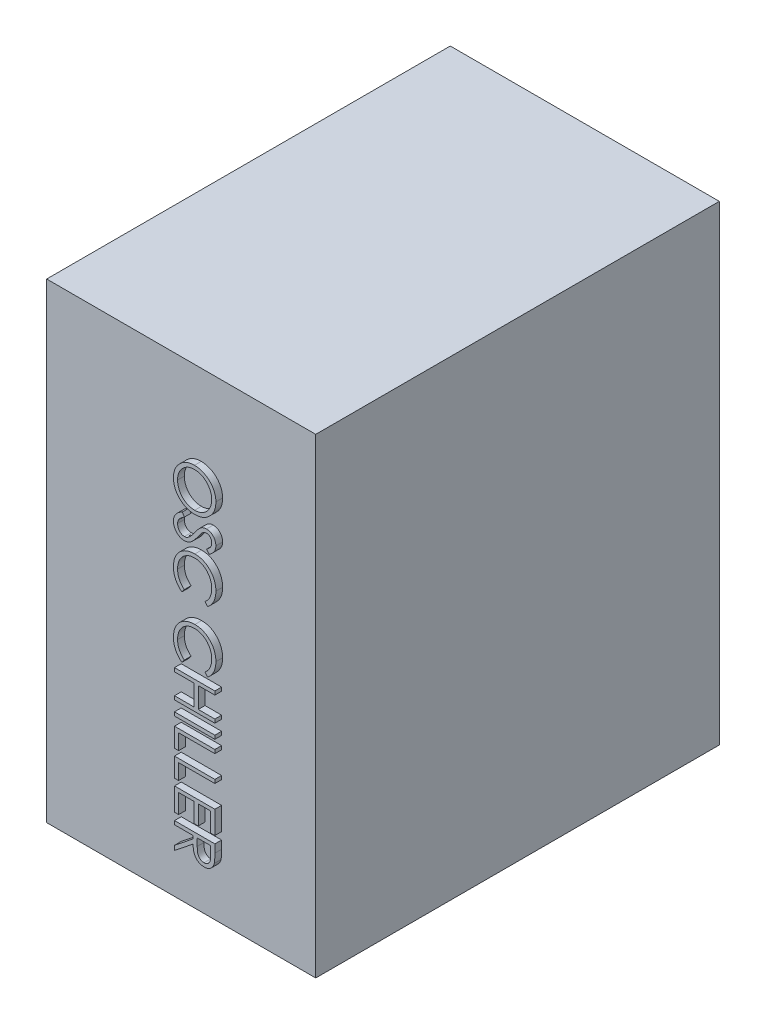
from build123d import *

# Parameters (mm, degrees)
SKETCH1_W           = 200
SKETCH1_H           = 350
BOSS_EXTRUDE1_DEPTH = 300
SKETCH2_W           = 30
SKETCH2_H           = 2.692307692
BOSS_EXTRUDE2_DEPTH = 5


with BuildPart() as part:
    # Sketch1 → Boss-Extrude1 (new body)
    with BuildSketch(Plane.XY):
        with Locations((-100, -175)):
            Rectangle(SKETCH1_W, SKETCH1_H)
    extrude(amount=BOSS_EXTRUDE1_DEPTH)

    # Sketch2 → Boss-Extrude2 (add)
    with BuildSketch(Plane.XY.offset(300)):
        with BuildLine():
            add(Edge.make_bspline(
                [(-69.230769231, -75.576923077), (-69.244839182, -76.132421016), (-69.272473727, -77.223464799), (-69.484007079, -78.82696551), (-69.849974239, -80.357774794), (-70.337346882, -81.828397209), (-70.987617266, -83.221115757), (-71.773152833, -84.546885839), (-72.705125751, -85.801958999), (-73.767897944, -86.974830976), (-74.92845251, -88.044179945), (-76.170543806, -88.978462774), (-77.47716333, -89.768391846), (-78.852857774, -90.41584132), (-80.291572216, -90.924230856), (-81.801486923, -91.274933956), (-83.37268077, -91.498983867), (-84.444340485, -91.525175057), (-84.987980769, -91.538461538)],
                knots=[0, 0, 0, 0, 0.001666225, 0.003272603, 0.004841055, 0.006382296, 0.007912212, 0.00944273, 0.010998049, 0.012593633, 0.014184377, 0.015725243, 0.017248535, 0.018756673, 0.0202791, 0.021816927, 0.023400287, 0.025030489, 0.025030489, 0.025030489, 0.025030489], degree=3))
            add(Edge.make_bspline(
                [(-84.987980769, -91.538461538), (-85.527616489, -91.525177027), (-86.59130101, -91.498991716), (-88.152523859, -91.274678956), (-89.653325755, -90.922931826), (-91.091055576, -90.420557273), (-92.467770578, -89.77621815), (-93.776791804, -88.980950308), (-95.027483464, -88.052853036), (-96.193671994, -86.987200176), (-97.265121686, -85.826922372), (-98.200857074, -84.581328469), (-99.000512052, -83.275994851), (-99.643520724, -81.901132042), (-100.155508264, -80.472067481), (-100.504909784, -78.975703847), (-100.730201885, -77.418718049), (-100.756078383, -76.356968702), (-100.769230769, -75.817307692)],
                knots=[0, 0, 0, 0, 0.001618194, 0.003189648, 0.004721629, 0.006236398, 0.007749974, 0.009273266, 0.010823759, 0.012414889, 0.014005633, 0.015554914, 0.01708132, 0.018589459, 0.020100551, 0.021626686, 0.023192188, 0.024810382, 0.024810382, 0.024810382, 0.024810382], degree=3))
            add(Edge.make_bspline(
                [(-100.769230769, -75.817307692), (-100.755952093, -75.27366961), (-100.729776286, -74.202014235), (-100.50533869, -72.628854888), (-100.154506943, -71.117846903), (-99.652654669, -69.673642651), (-99.006511212, -68.295768205), (-98.212496859, -66.984356826), (-97.276859994, -65.737832646), (-96.212625915, -64.568880493), (-95.051790493, -63.500616248), (-93.814383937, -62.561016158), (-92.512174692, -61.771579465), (-91.150530711, -61.125163242), (-89.732971608, -60.613872622), (-88.250580408, -60.264941869), (-86.71166376, -60.039213902), (-85.663868395, -60.013199728), (-85.132211538, -60)],
                knots=[0, 0, 0, 0, 0.001630202, 0.003213561, 0.004757237, 0.006277682, 0.007791258, 0.00931455, 0.010868637, 0.012459767, 0.014050512, 0.015594994, 0.017113145, 0.01861042, 0.020110189, 0.021624636, 0.023172284, 0.024766464, 0.024766464, 0.024766464, 0.024766464], degree=3))
            add(Edge.make_bspline(
                [(-85.132211538, -60), (-84.775358458, -60.004578388), (-84.066154158, -60.013677405), (-83.013035868, -60.123382311), (-81.976740292, -60.282250886), (-80.960750954, -60.51112543), (-79.964901947, -60.806354177), (-78.991229835, -61.170173523), (-78.031714423, -61.587110634), (-77.104616991, -62.083531858), (-76.208482392, -62.625142269), (-75.354516045, -63.215714005), (-74.557972095, -63.859364806), (-73.806051358, -64.546900273), (-73.111587411, -65.287837437), (-72.459439339, -66.071025216), (-71.856357941, -66.900561604), (-71.315009585, -67.777758534), (-70.817774543, -68.680251538), (-70.402624202, -69.614588245), (-70.035686975, -70.561055092), (-69.744080691, -71.527988928), (-69.512018673, -72.513153077), (-69.354338396, -73.517779101), (-69.244389729, -74.540832248), (-69.235328931, -75.230073544), (-69.230769231, -75.576923077)],
                knots=[0, 0, 0, 0, 0.001070133, 0.002126767, 0.003173079, 0.004214061, 0.005248449, 0.006286635, 0.007330666, 0.008384476, 0.009438833, 0.010470756, 0.011496589, 0.012508848, 0.0135249, 0.014540578, 0.015564755, 0.016598636, 0.017631258, 0.018653335, 0.019663397, 0.020674764, 0.021680598, 0.022697236, 0.023723966, 0.024764064, 0.024764064, 0.024764064, 0.024764064], degree=3))
        make_face()
        with BuildLine():
            add(Edge.make_bspline(
                [(-72.307692308, -75.709134615), (-72.311161143, -75.424437107), (-72.318065653, -74.857763817), (-72.409081928, -74.015334542), (-72.538674716, -73.183938934), (-72.724002335, -72.363622228), (-72.974187899, -71.558798867), (-73.268978217, -70.761431598), (-73.615754353, -69.975349097), (-74.020103961, -69.209339208), (-74.461811996, -68.464682316), (-74.946601873, -67.757196312), (-75.472122874, -67.093938849), (-76.031433215, -66.472785272), (-76.630223664, -65.895545614), (-77.25893748, -65.350518834), (-77.93567373, -64.859640764), (-78.642047093, -64.409763296), (-79.377146776, -64.007182101), (-80.133231198, -63.649193268), (-80.916468543, -63.356358927), (-81.718361315, -63.117538554), (-82.537639542, -62.919540176), (-83.380518246, -62.794106541), (-84.242762064, -62.702114889), (-84.82546367, -62.695601927), (-85.120192308, -62.692307692)],
                knots=[0, 0, 0, 0, 0.000853704, 0.001699246, 0.002539046, 0.003377317, 0.004219457, 0.005065618, 0.005926589, 0.006794828, 0.007662629, 0.008522761, 0.009365586, 0.01019956, 0.011028299, 0.011859387, 0.012693577, 0.013533828, 0.014370288, 0.015206403, 0.016041307, 0.016875951, 0.017715578, 0.018567249, 0.019430733, 0.020314473, 0.020314473, 0.020314473, 0.020314473], degree=3))
            add(Edge.make_bspline(
                [(-85.120192308, -62.692307692), (-85.553582772, -62.703235081), (-86.406195888, -62.724732634), (-87.655637122, -62.912940377), (-88.856393862, -63.202843016), (-90.001895941, -63.630191871), (-91.101989794, -64.164625711), (-92.146916406, -64.824856199), (-93.136958186, -65.607076932), (-94.065203349, -66.495621446), (-94.912453099, -67.466958931), (-95.656139459, -68.498382331), (-96.285370172, -69.578841823), (-96.797985078, -70.711154989), (-97.204182831, -71.889276752), (-97.482571097, -73.120798619), (-97.665789286, -74.397516844), (-97.683384337, -75.267779602), (-97.692307692, -75.709134615)],
                knots=[0, 0, 0, 0, 0.001299467, 0.002556454, 0.003782254, 0.004999108, 0.00621663, 0.007445446, 0.008699383, 0.009995804, 0.011294951, 0.012560828, 0.013804935, 0.01503938, 0.016284183, 0.017536406, 0.018822309, 0.020145531, 0.020145531, 0.020145531, 0.020145531], degree=3))
            add(Edge.make_bspline(
                [(-97.692307692, -75.709134615), (-97.688231953, -76.005787495), (-97.680148537, -76.594139252), (-97.59873113, -77.469243605), (-97.468172911, -78.328583029), (-97.280193421, -79.170949422), (-97.044940682, -79.995397021), (-96.765412245, -80.805328801), (-96.416842839, -81.592260445), (-96.03109703, -82.365579887), (-95.594507348, -83.1059351), (-95.116493864, -83.8083523), (-94.600371229, -84.468759284), (-94.045917856, -85.088586456), (-93.457913286, -85.66982574), (-92.821238949, -86.196694051), (-92.154488662, -86.693452761), (-91.446467682, -87.14152887), (-90.709818934, -87.543309664), (-89.950870561, -87.892682979), (-89.172230808, -88.189264173), (-88.372579981, -88.428639758), (-87.553489365, -88.616232563), (-86.713848051, -88.745488169), (-85.855339575, -88.835903587), (-85.274677928, -88.842718503), (-84.981971154, -88.846153846)],
                knots=[0, 0, 0, 0, 0.000889748, 0.001764637, 0.002634123, 0.003495848, 0.004351876, 0.005205262, 0.006063817, 0.00693191, 0.007796648, 0.008640073, 0.009479184, 0.010309142, 0.011133578, 0.011956895, 0.012786244, 0.013626494, 0.014468227, 0.01530181, 0.016131094, 0.016965738, 0.01780401, 0.018649744, 0.019513228, 0.020390961, 0.020390961, 0.020390961, 0.020390961], degree=3))
            add(Edge.make_bspline(
                [(-84.981971154, -88.846153846), (-84.691266832, -88.842715735), (-84.114601259, -88.835895608), (-83.262079958, -88.74553154), (-82.428481003, -88.616095337), (-81.617076977, -88.429557839), (-80.827661048, -88.18912795), (-80.060974639, -87.892665118), (-79.314161538, -87.543076837), (-78.589067565, -87.141863485), (-77.893284095, -86.690870713), (-77.228120564, -86.198062911), (-76.606068474, -85.654931362), (-76.011771179, -85.076993982), (-75.457903243, -84.449815054), (-74.944282823, -83.776235051), (-74.458507382, -83.064433392), (-74.020305588, -82.310766421), (-73.615547363, -81.532979649), (-73.269063138, -80.734791707), (-72.972912976, -79.923846499), (-72.725026393, -79.104296029), (-72.538493145, -78.270366891), (-72.409128423, -77.42691541), (-72.318055907, -76.572499908), (-72.311157803, -75.997836296), (-72.307692308, -75.709134615)],
                knots=[0, 0, 0, 0, 0.000871726, 0.001729229, 0.002569028, 0.003401441, 0.004224583, 0.005042641, 0.005865322, 0.00669652, 0.007526652, 0.008351175, 0.00917771, 0.010002145, 0.010836595, 0.011685207, 0.012541951, 0.013420096, 0.014299001, 0.015170975, 0.016028415, 0.016887811, 0.017737805, 0.018589476, 0.019446979, 0.020312697, 0.020312697, 0.020312697, 0.020312697], degree=3))
        make_face(mode=Mode.SUBTRACT)
        with BuildLine():
            Line((-94.212740385, -94.615384615), (-92.692307692, -97.151442308))
            add(Edge.make_bspline(
                [(-92.692307692, -97.151442308), (-93.087145278, -97.387312913), (-93.843638854, -97.83923189), (-94.865850629, -98.593100682), (-95.734669116, -99.374239921), (-96.445040037, -100.188434208), (-97.004316209, -101.030713764), (-97.400335338, -101.906577081), (-97.647329413, -102.813072602), (-97.677330155, -103.429991072), (-97.692307692, -103.737980769)],
                knots=[0, 0, 0, 0, 0.001379151, 0.0026424, 0.003803812, 0.004877399, 0.005875827, 0.00682529, 0.007750887, 0.008673672, 0.008673672, 0.008673672, 0.008673672], degree=3))
            add(Edge.make_bspline(
                [(-97.692307692, -103.737980769), (-97.684981937, -104.001011029), (-97.67045861, -104.522469138), (-97.530908744, -105.290145109), (-97.316519575, -106.035704915), (-97.00948112, -106.743773335), (-96.638015244, -107.404613179), (-96.189309619, -107.984027828), (-95.687056245, -108.485247563), (-95.126322424, -108.894119664), (-94.525354599, -109.211529727), (-93.902971508, -109.44121643), (-93.261910813, -109.587398203), (-92.827291013, -109.60600421), (-92.608173077, -109.615384615)],
                knots=[0, 0, 0, 0, 0.000788383, 0.001562971, 0.002333163, 0.003111217, 0.003873017, 0.004601446, 0.005302617, 0.005994975, 0.006675125, 0.007334897, 0.007980868, 0.008637678, 0.008637678, 0.008637678, 0.008637678], degree=3))
            add(Edge.make_bspline(
                [(-92.608173077, -109.615384615), (-92.358394365, -109.602747667), (-91.850630744, -109.577058596), (-91.101490861, -109.359931624), (-90.360125975, -109.018366651), (-89.901543699, -108.703258277), (-89.663461538, -108.539663462)],
                knots=[0, 0, 0, 0, 0.000748119, 0.001520816, 0.00232208, 0.003187236, 0.003187236, 0.003187236, 0.003187236], degree=3))
            add(Edge.make_bspline(
                [(-89.663461538, -108.539663462), (-89.49128036, -108.405724167), (-89.128746457, -108.123709978), (-88.598128141, -107.632166941), (-88.03742092, -107.070380755), (-87.448901697, -106.435542902), (-86.8433183, -105.715034125), (-86.20804728, -104.923649192), (-85.544997869, -104.057291433), (-85.106529765, -103.446721635), (-84.879807692, -103.131009615)],
                knots=[0, 0, 0, 0, 0.000654165, 0.00137737, 0.002167765, 0.003035317, 0.003973318, 0.004990702, 0.006079687, 0.007245691, 0.007245691, 0.007245691, 0.007245691], degree=3))
            add(Edge.make_bspline(
                [(-84.879807692, -103.131009615), (-84.654939769, -102.815417465), (-84.225009425, -102.212029305), (-83.587752235, -101.367554299), (-83.001405211, -100.613420214), (-82.47413595, -99.945784361), (-81.982947637, -99.381919327), (-81.554165222, -98.90121178), (-81.164892213, -98.521396842), (-80.912566756, -98.310038787), (-80.799278846, -98.215144231)],
                knots=[0, 0, 0, 0, 0.001162484, 0.002222581, 0.00317343, 0.004028445, 0.004774146, 0.0054165, 0.005960495, 0.006403742, 0.006403742, 0.006403742, 0.006403742], degree=3))
            add(Edge.make_bspline(
                [(-80.799278846, -98.215144231), (-80.62269853, -98.082522415), (-80.275429641, -97.821703814), (-79.732645146, -97.477423767), (-79.177017156, -97.184802372), (-78.607052603, -96.955410954), (-78.030753213, -96.762243363), (-77.440599678, -96.632318243), (-76.839240091, -96.550963412), (-76.434552943, -96.542632099), (-76.231971154, -96.538461538)],
                knots=[0, 0, 0, 0, 0.000662313, 0.001302528, 0.001926139, 0.002543289, 0.00314383, 0.00374743, 0.004353448, 0.004960895, 0.004960895, 0.004960895, 0.004960895], degree=3))
            add(Edge.make_bspline(
                [(-76.231971154, -96.538461538), (-75.914546511, -96.549600243), (-75.286481954, -96.57163957), (-74.369460405, -96.759552039), (-73.491277886, -97.052683073), (-72.671278081, -97.47663637), (-71.911378568, -98.000799625), (-71.223189369, -98.620278255), (-70.639724258, -99.355772773), (-70.135851409, -100.16725206), (-69.738022725, -101.049746606), (-69.436329048, -101.972837889), (-69.267663808, -102.940573698), (-69.243188261, -103.597142011), (-69.230769231, -103.930288462)],
                knots=[0, 0, 0, 0, 0.000951419, 0.001882502, 0.002796616, 0.003721179, 0.004641357, 0.005560219, 0.006487513, 0.007448149, 0.008418995, 0.00938447, 0.010354701, 0.011354106, 0.011354106, 0.011354106, 0.011354106], degree=3))
            add(Edge.make_bspline(
                [(-69.230769231, -103.930288462), (-69.242734118, -104.283862018), (-69.26646192, -104.98504066), (-69.480156343, -106.018378206), (-69.825340494, -107.01518196), (-70.222908912, -107.817560139), (-70.618205127, -108.444449792), (-70.978400721, -108.922493502), (-71.393036884, -109.406931255), (-71.863261246, -109.901656712), (-72.393375591, -110.398291151), (-72.979753119, -110.904206393), (-73.618809256, -111.420585858), (-74.07501927, -111.752778942), (-74.308894231, -111.923076923)],
                knots=[0, 0, 0, 0, 0.001059756, 0.002101623, 0.00315071, 0.004217683, 0.004779542, 0.005372091, 0.006011544, 0.006691667, 0.007418631, 0.008189761, 0.009014744, 0.009882546, 0.009882546, 0.009882546, 0.009882546], degree=3))
            Line((-74.308894231, -111.923076923), (-76.153846154, -109.489182692))
            add(Edge.make_bspline(
                [(-76.153846154, -109.489182692), (-75.964514516, -109.342217559), (-75.59990605, -109.059197073), (-75.089294843, -108.629515734), (-74.622867639, -108.224527399), (-74.217738754, -107.825523723), (-73.851717907, -107.453579126), (-73.538356979, -107.092573227), (-73.274538831, -106.747716061), (-72.993136677, -106.312963361), (-72.712417205, -105.765372829), (-72.479933556, -105.078666378), (-72.335196286, -104.362994221), (-72.31696108, -103.876889737), (-72.307692308, -103.629807692)],
                knots=[0, 0, 0, 0, 0.000718947, 0.001384524, 0.002001878, 0.002571367, 0.003089868, 0.003567018, 0.004004524, 0.004391247, 0.005119601, 0.005843679, 0.006560261, 0.007301005, 0.007301005, 0.007301005, 0.007301005], degree=3))
            add(Edge.make_bspline(
                [(-72.307692308, -103.629807692), (-72.318078307, -103.319894643), (-72.338106729, -102.722256522), (-72.55684946, -101.873768784), (-72.901265406, -101.11010657), (-73.383965218, -100.453941726), (-73.955859441, -99.90762478), (-74.613963913, -99.512435134), (-75.340670221, -99.27457658), (-75.847598704, -99.245551326), (-76.105769231, -99.230769231)],
                knots=[0, 0, 0, 0, 0.000927839, 0.00178925, 0.002609402, 0.003426798, 0.004217605, 0.004966882, 0.00571188, 0.006485068, 0.006485068, 0.006485068, 0.006485068], degree=3))
            add(Edge.make_bspline(
                [(-76.105769231, -99.230769231), (-76.266455212, -99.234295757), (-76.588089927, -99.241354577), (-77.064529679, -99.333162064), (-77.536740241, -99.46334232), (-78.006821339, -99.653869143), (-78.485831991, -99.910500217), (-78.972478926, -100.259441331), (-79.479048809, -100.695981029), (-79.808192958, -101.031034534), (-79.981971154, -101.207932692)],
                knots=[0, 0, 0, 0, 0.00048137, 0.000963527, 0.001450565, 0.001949399, 0.002481785, 0.00307701, 0.003741881, 0.004485545, 0.004485545, 0.004485545, 0.004485545], degree=3))
            add(Edge.make_bspline(
                [(-79.981971154, -101.207932692), (-80.040574232, -101.273601599), (-80.179801732, -101.429615888), (-80.407735566, -101.714838109), (-80.688902186, -102.091490665), (-81.03679347, -102.549738104), (-81.44034886, -103.098029776), (-81.894408392, -103.736425971), (-82.413712327, -104.457810539), (-82.776776961, -104.969712675), (-82.96875, -105.240384615)],
                knots=[0, 0, 0, 0, 0.000264013, 0.000627234, 0.001094789, 0.001674117, 0.00235323, 0.003137065, 0.004024292, 0.005019805, 0.005019805, 0.005019805, 0.005019805], degree=3))
            add(Edge.make_bspline(
                [(-82.96875, -105.240384615), (-83.205675939, -105.565978158), (-83.664450183, -106.196444927), (-84.35372744, -107.093509898), (-85.027851171, -107.906885396), (-85.682516374, -108.63942714), (-86.312757171, -109.29837207), (-86.92615586, -109.876409676), (-87.518317912, -110.379429793), (-88.277511417, -110.920965951), (-89.209920711, -111.47431869), (-90.352305613, -111.949531611), (-91.499131217, -112.249174589), (-92.269932673, -112.288359007), (-92.650240385, -112.307692308)],
                knots=[0, 0, 0, 0, 0.001207992, 0.00233911, 0.003393262, 0.004376436, 0.005285975, 0.00612775, 0.006904131, 0.007614614, 0.008923607, 0.010146797, 0.011317207, 0.012457087, 0.012457087, 0.012457087, 0.012457087], degree=3))
            add(Edge.make_bspline(
                [(-92.650240385, -112.307692308), (-92.919195679, -112.302056566), (-93.451883339, -112.290894525), (-94.234100545, -112.162703623), (-94.993679043, -111.974651555), (-95.721918028, -111.692109017), (-96.428561941, -111.344555004), (-97.107101593, -110.915275913), (-97.748209184, -110.397780245), (-98.365226098, -109.82260477), (-98.922569761, -109.183393646), (-99.421051245, -108.509406688), (-99.838277116, -107.796268298), (-100.174145018, -107.047430148), (-100.440993804, -106.267034656), (-100.632799136, -105.454260543), (-100.750787971, -104.606844478), (-100.763014539, -104.030835273), (-100.769230769, -103.737980769)],
                knots=[0, 0, 0, 0, 0.000806095, 0.001596537, 0.002371964, 0.003149901, 0.00393468, 0.004731605, 0.005552836, 0.006403107, 0.007259029, 0.008093219, 0.008914692, 0.009732353, 0.010551448, 0.011385227, 0.012234286, 0.01311243, 0.01311243, 0.01311243, 0.01311243], degree=3))
            add(Edge.make_bspline(
                [(-100.769230769, -103.737980769), (-100.764799007, -103.511402115), (-100.755991297, -103.061098332), (-100.67997017, -102.396832354), (-100.568484262, -101.744764316), (-100.398508633, -101.113081715), (-100.187425898, -100.493918957), (-99.928985629, -99.89279507), (-99.621325626, -99.308249593), (-99.263936304, -98.739599939), (-98.852057703, -98.181487792), (-98.376071977, -97.636774435), (-97.839266855, -97.099228296), (-97.236137273, -96.578703427), (-96.573127057, -96.065605196), (-95.844680829, -95.569475587), (-95.054579999, -95.080211945), (-94.498594855, -94.773221058), (-94.212740385, -94.615384615)],
                knots=[0, 0, 0, 0, 0.000679512, 0.001350466, 0.002003554, 0.002662423, 0.003310487, 0.003964652, 0.004623247, 0.005290206, 0.005977722, 0.006701925, 0.007458325, 0.008254888, 0.009090311, 0.009972108, 0.010897706, 0.011877181, 0.011877181, 0.011877181, 0.011877181], degree=3))
        make_face()
        with BuildLine():
            Line((-75.504807692, -146.153846154), (-77.307692308, -143.798076923))
            add(Edge.make_bspline(
                [(-77.307692308, -143.798076923), (-77.107412566, -143.630026451), (-76.709553289, -143.296191193), (-76.150871479, -142.759112314), (-75.627454952, -142.199383946), (-75.13681027, -141.61722005), (-74.696095135, -141.002141883), (-74.282342824, -140.369049323), (-73.911476499, -139.707351793), (-73.461793761, -138.792336925), (-72.992541003, -137.595355368), (-72.599084735, -136.088542462), (-72.348617515, -134.515590189), (-72.321490302, -133.442467906), (-72.307692308, -132.896634615)],
                knots=[0, 0, 0, 0, 0.000784157, 0.001557742, 0.002323066, 0.003082516, 0.003839823, 0.004591601, 0.005350433, 0.006113725, 0.007649331, 0.0091974, 0.010778282, 0.012414764, 0.012414764, 0.012414764, 0.012414764], degree=3))
            add(Edge.make_bspline(
                [(-72.307692308, -132.896634615), (-72.311170467, -132.595924276), (-72.318094506, -131.997294474), (-72.408799291, -131.108825042), (-72.537754174, -130.235263331), (-72.724443141, -129.379857807), (-72.967495238, -128.544306917), (-73.252530473, -127.722248631), (-73.607227895, -126.923364604), (-73.998943843, -126.138040472), (-74.441510876, -125.385681972), (-74.924084567, -124.673670738), (-75.441928528, -124.005259614), (-75.993706049, -123.378596414), (-76.586274614, -122.800553856), (-77.212663356, -122.261867945), (-77.880411642, -121.772247071), (-78.576996415, -121.319659654), (-79.303441518, -120.9169378), (-80.055177007, -120.569167979), (-80.829328725, -120.271100328), (-81.627482571, -120.033060176), (-82.446497616, -119.845303038), (-83.288111995, -119.715591875), (-84.150692089, -119.625703062), (-84.735342563, -119.618842718), (-85.030048077, -119.615384615)],
                knots=[0, 0, 0, 0, 0.000901763, 0.001795156, 0.002676523, 0.003549987, 0.004419224, 0.005285943, 0.006157917, 0.007039448, 0.007917592, 0.008774337, 0.00961819, 0.01045264, 0.011277075, 0.01209969, 0.012929039, 0.013759171, 0.014590369, 0.015418497, 0.016242165, 0.01707681, 0.017915081, 0.018760816, 0.019630281, 0.020514021, 0.020514021, 0.020514021, 0.020514021], degree=3))
            add(Edge.make_bspline(
                [(-85.030048077, -119.615384615), (-85.473459391, -119.626200207), (-86.344038689, -119.647435187), (-87.619215351, -119.836420907), (-88.840821126, -120.123607404), (-90.001219775, -120.554026635), (-91.114719987, -121.084761354), (-92.162481587, -121.755395167), (-93.160337854, -122.532108344), (-94.084705978, -123.425889083), (-94.929109338, -124.406510362), (-95.672685751, -125.458635319), (-96.2925276, -126.5796435), (-96.808321428, -127.757157473), (-97.204807665, -129.000238449), (-97.483928723, -130.306651042), (-97.666004557, -131.673553858), (-97.683436169, -132.607577286), (-97.692307692, -133.082932692)],
                knots=[0, 0, 0, 0, 0.001329484, 0.002610265, 0.003859413, 0.005087552, 0.006315883, 0.007552988, 0.008811655, 0.010103736, 0.011403495, 0.012688963, 0.013961441, 0.01523981, 0.016539777, 0.017868228, 0.019243498, 0.020668804, 0.020668804, 0.020668804, 0.020668804], degree=3))
            add(Edge.make_bspline(
                [(-97.692307692, -133.082932692), (-97.677832437, -133.606670027), (-97.649341673, -134.637510389), (-97.40797668, -136.149236329), (-97.016623099, -137.596400034), (-96.468926622, -138.979079347), (-95.75693844, -140.293376315), (-94.893813776, -141.541347689), (-93.871342353, -142.724046865), (-93.090629825, -143.435229284), (-92.692307692, -143.798076923)],
                knots=[0, 0, 0, 0, 0.001570454, 0.003091029, 0.004579498, 0.006060378, 0.00754194, 0.009053905, 0.010604642, 0.012219988, 0.012219988, 0.012219988, 0.012219988], degree=3))
            Line((-92.692307692, -143.798076923), (-94.477163462, -146.153846154))
            add(Edge.make_bspline(
                [(-94.477163462, -146.153846154), (-94.721779182, -145.964262607), (-95.209838927, -145.586003606), (-95.897875952, -144.973502585), (-96.545076565, -144.328282551), (-97.146084268, -143.645467445), (-97.713445719, -142.933223741), (-98.22814058, -142.179005623), (-98.705847279, -141.395839903), (-99.137473862, -140.579166873), (-99.52447446, -139.731667779), (-99.851191065, -138.8542246), (-100.136680438, -137.954271082), (-100.369996599, -137.031354004), (-100.552394184, -136.082390154), (-100.674256793, -135.11063545), (-100.757764402, -134.114038621), (-100.765374359, -133.441683295), (-100.769230769, -133.100961538)],
                knots=[0, 0, 0, 0, 0.000928228, 0.00185201, 0.00276139, 0.003668205, 0.004579548, 0.005491368, 0.00640556, 0.007330338, 0.008260898, 0.009198494, 0.010137418, 0.011092115, 0.012052696, 0.013034399, 0.014029058, 0.015050976, 0.015050976, 0.015050976, 0.015050976], degree=3))
            add(Edge.make_bspline(
                [(-100.769230769, -133.100961538), (-100.766985119, -132.778301535), (-100.762544623, -132.140281334), (-100.690611759, -131.198292035), (-100.592471157, -130.281238485), (-100.444698605, -129.391741692), (-100.270318548, -128.52494762), (-100.03656492, -127.688714039), (-99.77471492, -126.874812236), (-99.466957891, -126.086512173), (-99.119676326, -125.323143317), (-98.72717725, -124.587167791), (-98.292761267, -123.878924085), (-97.826004035, -123.191449049), (-97.311912876, -122.534898332), (-96.757627438, -121.9035824), (-96.165015917, -121.293961175), (-95.737688602, -120.916795304), (-95.522836538, -120.727163462)],
                knots=[0, 0, 0, 0, 0.000967716, 0.001913539, 0.002832695, 0.003733737, 0.004617702, 0.005483692, 0.006336994, 0.00718181, 0.008020856, 0.008851597, 0.009682316, 0.010512427, 0.011343103, 0.012182063, 0.013031994, 0.013891432, 0.013891432, 0.013891432, 0.013891432], degree=3))
            add(Edge.make_bspline(
                [(-95.522836538, -120.727163462), (-95.149626348, -120.423429374), (-94.407711687, -119.819628144), (-93.205260419, -119.047122285), (-91.949818629, -118.385857526), (-90.634790668, -117.851206777), (-89.263127349, -117.433240493), (-87.834137225, -117.143687392), (-86.349154863, -116.955530782), (-85.339125246, -116.934014021), (-84.825721154, -116.923076923)],
                knots=[0, 0, 0, 0, 0.001442621, 0.002867825, 0.004279061, 0.005694131, 0.007119943, 0.008574344, 0.010063662, 0.011603297, 0.011603297, 0.011603297, 0.011603297], degree=3))
            add(Edge.make_bspline(
                [(-84.825721154, -116.923076923), (-84.286125557, -116.936466776), (-83.224504907, -116.962810476), (-81.666120223, -117.184780607), (-80.175225931, -117.546190862), (-78.746085424, -118.043855192), (-77.386875702, -118.700407503), (-76.091856249, -119.495217173), (-74.862084485, -120.436047571), (-73.713283157, -121.511082766), (-72.662973833, -122.690293476), (-71.738913341, -123.953009924), (-70.969907991, -125.296859467), (-70.327083224, -126.707011332), (-69.832987966, -128.194031772), (-69.48710347, -129.754746278), (-69.271813912, -131.386222714), (-69.244597843, -132.499329217), (-69.230769231, -133.064903846)],
                knots=[0, 0, 0, 0, 0.001618194, 0.003183696, 0.004711238, 0.006214663, 0.007714529, 0.00923068, 0.010765593, 0.012351596, 0.013943634, 0.015496687, 0.017036697, 0.018580501, 0.020138835, 0.021728012, 0.023370144, 0.025066389, 0.025066389, 0.025066389, 0.025066389], degree=3))
            add(Edge.make_bspline(
                [(-69.230769231, -133.064903846), (-69.234898756, -133.409599995), (-69.243072734, -134.091891309), (-69.322884432, -135.101189969), (-69.455693622, -136.083874477), (-69.637651193, -137.04232132), (-69.860670179, -137.980006023), (-70.152619266, -138.887308642), (-70.491643728, -139.769169781), (-70.87215006, -140.626249905), (-71.30715598, -141.44922424), (-71.779618008, -142.237943016), (-72.300442147, -142.982891786), (-72.852409936, -143.698083085), (-73.456168594, -144.367415692), (-74.092056253, -145.010005583), (-74.778941926, -145.603655281), (-75.262409524, -145.970113477), (-75.504807692, -146.153846154)],
                knots=[0, 0, 0, 0, 0.001033933, 0.002046567, 0.003035016, 0.004007405, 0.004972318, 0.005924515, 0.006864246, 0.007805763, 0.008735857, 0.009655191, 0.010562065, 0.011461261, 0.012363584, 0.013264466, 0.014171838, 0.015084212, 0.015084212, 0.015084212, 0.015084212], degree=3))
        make_face()
        with BuildLine():
            Line((-75.504807692, -191.538461538), (-77.307692308, -189.182692308))
            add(Edge.make_bspline(
                [(-77.307692308, -189.182692308), (-77.107412566, -189.014641836), (-76.709553289, -188.680806578), (-76.150871479, -188.143727699), (-75.627454952, -187.583999331), (-75.13681027, -187.001835435), (-74.696095135, -186.386757268), (-74.282342824, -185.753664708), (-73.911476499, -185.091967178), (-73.461793761, -184.176952309), (-72.992541003, -182.979970753), (-72.599084735, -181.473157846), (-72.348617515, -179.900205573), (-72.321490302, -178.827083291), (-72.307692308, -178.28125)],
                knots=[0, 0, 0, 0, 0.000784157, 0.001557742, 0.002323066, 0.003082516, 0.003839823, 0.004591601, 0.005350433, 0.006113725, 0.007649331, 0.0091974, 0.010778282, 0.012414764, 0.012414764, 0.012414764, 0.012414764], degree=3))
            add(Edge.make_bspline(
                [(-72.307692308, -178.28125), (-72.311170467, -177.980539661), (-72.318094506, -177.381909858), (-72.408799291, -176.493440427), (-72.537754174, -175.619878716), (-72.724443141, -174.764473192), (-72.967495238, -173.928922301), (-73.252530473, -173.106864016), (-73.607227895, -172.307979989), (-73.998943843, -171.522655857), (-74.441510876, -170.770297356), (-74.924084567, -170.058286123), (-75.441928528, -169.389874998), (-75.993706049, -168.763211799), (-76.586274614, -168.185169241), (-77.212663356, -167.64648333), (-77.880411642, -167.156862456), (-78.576996415, -166.704275039), (-79.303441518, -166.301553184), (-80.055177007, -165.953783364), (-80.829328725, -165.655715713), (-81.627482571, -165.417675561), (-82.446497616, -165.229918423), (-83.288111995, -165.100207259), (-84.150692089, -165.010318447), (-84.735342563, -165.003458103), (-85.030048077, -165)],
                knots=[0, 0, 0, 0, 0.000901763, 0.001795156, 0.002676523, 0.003549987, 0.004419224, 0.005285943, 0.006157917, 0.007039448, 0.007917592, 0.008774337, 0.00961819, 0.01045264, 0.011277075, 0.01209969, 0.012929039, 0.013759171, 0.014590369, 0.015418497, 0.016242165, 0.01707681, 0.017915081, 0.018760816, 0.019630281, 0.020514021, 0.020514021, 0.020514021, 0.020514021], degree=3))
            add(Edge.make_bspline(
                [(-85.030048077, -165), (-85.473459391, -165.010815592), (-86.344038689, -165.032050571), (-87.619215351, -165.221036292), (-88.840821126, -165.508222789), (-90.001219775, -165.93864202), (-91.114719987, -166.469376739), (-92.162481587, -167.140010552), (-93.160337854, -167.916723729), (-94.084705978, -168.810504467), (-94.929109338, -169.791125747), (-95.672685751, -170.843250704), (-96.2925276, -171.964258885), (-96.808321428, -173.141772858), (-97.204807665, -174.384853834), (-97.483928723, -175.691266426), (-97.666004557, -177.058169243), (-97.683436169, -177.99219267), (-97.692307692, -178.467548077)],
                knots=[0, 0, 0, 0, 0.001329484, 0.002610265, 0.003859413, 0.005087552, 0.006315883, 0.007552988, 0.008811655, 0.010103736, 0.011403495, 0.012688963, 0.013961441, 0.01523981, 0.016539777, 0.017868228, 0.019243498, 0.020668804, 0.020668804, 0.020668804, 0.020668804], degree=3))
            add(Edge.make_bspline(
                [(-97.692307692, -178.467548077), (-97.677832437, -178.991285411), (-97.649341673, -180.022125773), (-97.40797668, -181.533851713), (-97.016623099, -182.981015419), (-96.468926622, -184.363694732), (-95.75693844, -185.677991699), (-94.893813776, -186.925963074), (-93.871342353, -188.108662249), (-93.090629825, -188.819844668), (-92.692307692, -189.182692308)],
                knots=[0, 0, 0, 0, 0.001570454, 0.003091029, 0.004579498, 0.006060378, 0.00754194, 0.009053905, 0.010604642, 0.012219988, 0.012219988, 0.012219988, 0.012219988], degree=3))
            Line((-92.692307692, -189.182692308), (-94.477163462, -191.538461538))
            add(Edge.make_bspline(
                [(-94.477163462, -191.538461538), (-94.721779182, -191.348877991), (-95.209838927, -190.970618991), (-95.897875952, -190.35811797), (-96.545076565, -189.712897935), (-97.146084268, -189.030082829), (-97.713445719, -188.317839126), (-98.22814058, -187.563621008), (-98.705847279, -186.780455287), (-99.137473862, -185.963782258), (-99.52447446, -185.116283164), (-99.851191065, -184.238839984), (-100.136680438, -183.338886467), (-100.369996599, -182.415969389), (-100.552394184, -181.467005539), (-100.674256793, -180.495250835), (-100.757764402, -179.498654005), (-100.765374359, -178.82629868), (-100.769230769, -178.485576923)],
                knots=[0, 0, 0, 0, 0.000928228, 0.00185201, 0.00276139, 0.003668205, 0.004579548, 0.005491368, 0.00640556, 0.007330338, 0.008260898, 0.009198494, 0.010137418, 0.011092115, 0.012052696, 0.013034399, 0.014029058, 0.015050976, 0.015050976, 0.015050976, 0.015050976], degree=3))
            add(Edge.make_bspline(
                [(-100.769230769, -178.485576923), (-100.766985119, -178.16291692), (-100.762544623, -177.524896719), (-100.690611759, -176.582907419), (-100.592471157, -175.66585387), (-100.444698605, -174.776357076), (-100.270318548, -173.909563005), (-100.03656492, -173.073329423), (-99.77471492, -172.25942762), (-99.466957891, -171.471127557), (-99.119676326, -170.707758702), (-98.72717725, -169.971783176), (-98.292761267, -169.263539469), (-97.826004035, -168.576064434), (-97.311912876, -167.919513716), (-96.757627438, -167.288197785), (-96.165015917, -166.67857656), (-95.737688602, -166.301410689), (-95.522836538, -166.111778846)],
                knots=[0, 0, 0, 0, 0.000967716, 0.001913539, 0.002832695, 0.003733737, 0.004617702, 0.005483692, 0.006336994, 0.00718181, 0.008020856, 0.008851597, 0.009682316, 0.010512427, 0.011343103, 0.012182063, 0.013031994, 0.013891432, 0.013891432, 0.013891432, 0.013891432], degree=3))
            add(Edge.make_bspline(
                [(-95.522836538, -166.111778846), (-95.149626348, -165.808044759), (-94.407711687, -165.204243529), (-93.205260419, -164.43173767), (-91.949818629, -163.770472911), (-90.634790668, -163.235822162), (-89.263127349, -162.817855877), (-87.834137225, -162.528302777), (-86.349154863, -162.340146167), (-85.339125246, -162.318629406), (-84.825721154, -162.307692308)],
                knots=[0, 0, 0, 0, 0.001442621, 0.002867825, 0.004279061, 0.005694131, 0.007119943, 0.008574344, 0.010063662, 0.011603297, 0.011603297, 0.011603297, 0.011603297], degree=3))
            add(Edge.make_bspline(
                [(-84.825721154, -162.307692308), (-84.286125557, -162.321082161), (-83.224504907, -162.347425861), (-81.666120223, -162.569395992), (-80.175225931, -162.930806247), (-78.746085424, -163.428470577), (-77.386875702, -164.085022888), (-76.091856249, -164.879832558), (-74.862084485, -165.820662956), (-73.713283157, -166.895698151), (-72.662973833, -168.07490886), (-71.738913341, -169.337625309), (-70.969907991, -170.681474851), (-70.327083224, -172.091626717), (-69.832987966, -173.578647156), (-69.48710347, -175.139361663), (-69.271813912, -176.770838099), (-69.244597843, -177.883944601), (-69.230769231, -178.449519231)],
                knots=[0, 0, 0, 0, 0.001618194, 0.003183696, 0.004711238, 0.006214663, 0.007714529, 0.00923068, 0.010765593, 0.012351596, 0.013943634, 0.015496687, 0.017036697, 0.018580501, 0.020138835, 0.021728012, 0.023370144, 0.025066389, 0.025066389, 0.025066389, 0.025066389], degree=3))
            add(Edge.make_bspline(
                [(-69.230769231, -178.449519231), (-69.234898756, -178.79421538), (-69.243072734, -179.476506694), (-69.322884432, -180.485805353), (-69.455693622, -181.468489861), (-69.637651193, -182.426936704), (-69.860670179, -183.364621407), (-70.152619266, -184.271924027), (-70.491643728, -185.153785166), (-70.87215006, -186.01086529), (-71.30715598, -186.833839624), (-71.779618008, -187.622558401), (-72.300442147, -188.367507171), (-72.852409936, -189.082698469), (-73.456168594, -189.752031077), (-74.092056253, -190.394620967), (-74.778941926, -190.988270665), (-75.262409524, -191.354728862), (-75.504807692, -191.538461538)],
                knots=[0, 0, 0, 0, 0.001033933, 0.002046567, 0.003035016, 0.004007405, 0.004972318, 0.005924515, 0.006864246, 0.007805763, 0.008735857, 0.009655191, 0.010562065, 0.011461261, 0.012363584, 0.013264466, 0.014171838, 0.015084212, 0.015084212, 0.015084212, 0.015084212], degree=3))
        make_face()
        Polygon((-70, -197.692307692), (-70, -200.384615385), (-82.307692308, -200.384615385), (-82.307692308, -215.769230769), (-70, -215.769230769), (-70, -218.461538462), (-100, -218.461538462), (-100, -215.769230769), (-85.384615385, -215.769230769), (-85.384615385, -200.384615385), (-100, -200.384615385), (-100, -197.692307692), align=None)
        with Locations((-85, -227.5)):
            Rectangle(SKETCH2_W, SKETCH2_H)
        Polygon((-70, -235.384615385), (-70, -238.076923077), (-96.923076923, -238.076923077), (-96.923076923, -249.615384615), (-100, -249.615384615), (-100, -235.384615385), align=None)
        Polygon((-70, -254.615384615), (-70, -257.307692308), (-96.923076923, -257.307692308), (-96.923076923, -268.846153846), (-100, -268.846153846), (-100, -254.615384615), align=None)
        Polygon((-70, -273.846153846), (-70, -290.769230769), (-73.076923077, -290.769230769), (-73.076923077, -276.538461538), (-82.307692308, -276.538461538), (-82.307692308, -290.769230769), (-85.384615385, -290.769230769), (-85.384615385, -276.538461538), (-96.923076923, -276.538461538), (-96.923076923, -290.769230769), (-100, -290.769230769), (-100, -273.846153846), align=None)
        with BuildLine():
            Line((-70, -296.153846154), (-70, -302.157451923))
            add(Edge.make_bspline(
                [(-70, -302.157451923), (-70.001333594, -302.558090167), (-70.003894243, -303.327359977), (-70.018172211, -304.42941658), (-70.059095259, -305.430791697), (-70.094311689, -306.330961748), (-70.158528329, -307.129910219), (-70.219905304, -307.830086997), (-70.300250968, -308.428267262), (-70.374868879, -308.790374558), (-70.408653846, -308.954326923)],
                knots=[0, 0, 0, 0, 0.001201938, 0.002307854, 0.003306102, 0.004208525, 0.00501006, 0.005710303, 0.006317125, 0.006819207, 0.006819207, 0.006819207, 0.006819207], degree=3))
            add(Edge.make_bspline(
                [(-70.408653846, -308.954326923), (-70.462877112, -309.173816139), (-70.570166913, -309.60811227), (-70.797052743, -310.233342462), (-71.05917739, -310.829386451), (-71.369442173, -311.394007458), (-71.722435407, -311.92725786), (-72.120219502, -312.428339237), (-72.564820221, -312.894386763), (-73.044884334, -313.328986448), (-73.564600544, -313.722937076), (-74.116397994, -314.0638498), (-74.696825515, -314.355771654), (-75.307904369, -314.588821649), (-75.944468889, -314.776303226), (-76.612077484, -314.908540242), (-77.307745656, -314.987832789), (-77.782241648, -314.995906298), (-78.022836538, -315)],
                knots=[0, 0, 0, 0, 0.000677836, 0.001341211, 0.001992277, 0.002629693, 0.003271401, 0.003908675, 0.004546318, 0.005201614, 0.005849455, 0.006499855, 0.007144875, 0.007795525, 0.008459227, 0.009133376, 0.009834856, 0.01055641, 0.01055641, 0.01055641, 0.01055641], degree=3))
            add(Edge.make_bspline(
                [(-78.022836538, -315), (-78.422566467, -314.987408914), (-79.202543089, -314.962840445), (-80.334487076, -314.733763564), (-81.390418982, -314.358552943), (-82.368869317, -313.841434685), (-83.251280919, -313.183209624), (-84.023710393, -312.392172777), (-84.676062277, -311.472363915), (-85.123633165, -310.612062019), (-85.411619459, -309.851755871), (-85.615264878, -309.223987271), (-85.76995325, -308.538677865), (-85.910543367, -307.805659457), (-86.01782492, -307.019270139), (-86.094015213, -306.181093506), (-86.14300615, -305.28903323), (-86.150163936, -304.677549558), (-86.153846154, -304.362980769)],
                knots=[0, 0, 0, 0, 0.001198086, 0.002337776, 0.003447848, 0.004550084, 0.005645039, 0.006737219, 0.007852889, 0.009016724, 0.009635014, 0.010290723, 0.010994772, 0.01174086, 0.012529564, 0.013374529, 0.014265251, 0.015208933, 0.015208933, 0.015208933, 0.015208933], degree=3))
            Line((-86.153846154, -304.362980769), (-100, -315.384615385))
            Line((-100, -315.384615385), (-100, -312.055288462))
            Line((-100, -312.055288462), (-86.153846154, -301.033653846))
            Line((-86.153846154, -301.033653846), (-86.153846154, -298.846153846))
            Line((-86.153846154, -298.846153846), (-100, -298.846153846))
            Line((-100, -298.846153846), (-100, -296.153846154))
            Line((-100, -296.153846154), (-70, -296.153846154))
        make_face()
        with BuildLine():
            Line((-73.076923077, -298.846153846), (-83.076923077, -298.846153846))
            Line((-83.076923077, -298.846153846), (-83.118990385, -304.338942308))
            add(Edge.make_bspline(
                [(-83.118990385, -304.338942308), (-83.119103841, -304.595399783), (-83.119323751, -305.092487413), (-83.085091395, -305.811635983), (-83.046148629, -306.481236892), (-82.986582936, -307.098729217), (-82.909816193, -307.664387896), (-82.813791964, -308.177933194), (-82.701912741, -308.64019363), (-82.528774487, -309.179348071), (-82.254311867, -309.78121249), (-81.85567055, -310.436121431), (-81.351022335, -310.991937203), (-80.783136346, -311.471158126), (-80.145915887, -311.840280291), (-79.467644774, -312.108936465), (-78.754178744, -312.277533185), (-78.264134368, -312.297576953), (-78.016826923, -312.307692308)],
                knots=[0, 0, 0, 0, 0.000769254, 0.001491034, 0.002159426, 0.002781327, 0.003351608, 0.003871396, 0.004348016, 0.004777524, 0.005568331, 0.00632702, 0.007067643, 0.007810165, 0.008548149, 0.009265714, 0.009993175, 0.010734334, 0.010734334, 0.010734334, 0.010734334], degree=3))
            add(Edge.make_bspline(
                [(-78.016826923, -312.307692308), (-77.775503673, -312.297545859), (-77.297289048, -312.2774393), (-76.599116736, -312.108609803), (-75.935457923, -311.835974848), (-75.318962389, -311.453677546), (-74.754688173, -310.99172989), (-74.278554598, -310.44309836), (-73.87982048, -309.835412711), (-73.626876392, -309.267039378), (-73.471488824, -308.759369468), (-73.362278846, -308.318522841), (-73.273797286, -307.818510527), (-73.205004546, -307.260530827), (-73.14309894, -306.645593219), (-73.102960985, -305.972013885), (-73.078701599, -305.240570661), (-73.077529714, -304.733594813), (-73.076923077, -304.471153846)],
                knots=[0, 0, 0, 0, 0.000723179, 0.001433077, 0.002141753, 0.002867351, 0.00360141, 0.004321085, 0.005037843, 0.005774947, 0.006177905, 0.006629746, 0.007136624, 0.007700152, 0.008316072, 0.008990462, 0.009724029, 0.010511312, 0.010511312, 0.010511312, 0.010511312], degree=3))
            Line((-73.076923077, -304.471153846), (-73.076923077, -298.846153846))
        make_face(mode=Mode.SUBTRACT)
    extrude(amount=BOSS_EXTRUDE2_DEPTH)


solid = part.part
